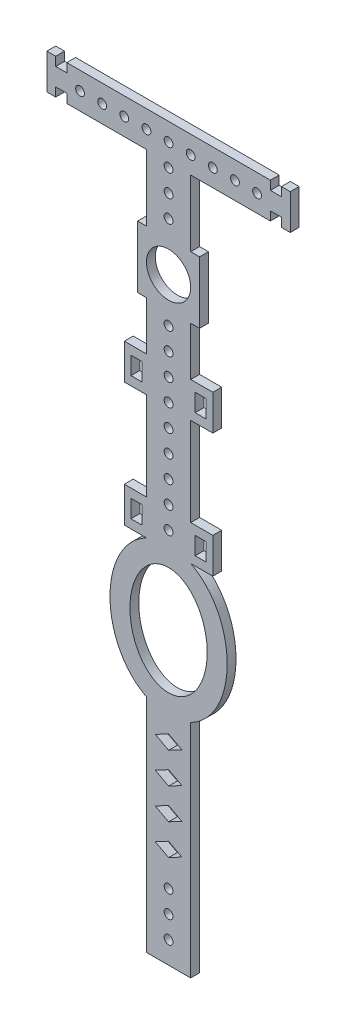
from build123d import *

# Parameters (mm, degrees)
SKETCH_1_R      = 5
SKETCH_1_R_2    = 1
SKETCH_1_W      = 2.5
SKETCH_1_H      = 4
EXTRUDE_1_DEPTH = 2


with BuildPart() as part:
    # 草图1 → 凸台-拉伸1 (new body)
    with BuildSketch(Plane.XY):
        with BuildLine():
            Line((-5, 7), (-7, 7))
            Line((-7, 7), (-7, -7))
            Line((-7, -7), (-5, -7))
            Line((-5, -7), (-5, -18))
            Line((-5, -18), (-10, -18))
            Line((-10, -18), (-10, -26))
            Line((-10, -26), (-5, -26))
            Line((-5, -26), (-5, -46))
            Line((-5, -46), (-10, -46))
            Line((-10, -46), (-10, -54))
            Line((-10, -54), (-5, -54))
            add(Edge.make_bspline(
                [(-5, -54), (-5.206631572, -54.1046163), (-7.122538881, -55.146340962), (-10.136236083, -58.053937604), (-12.460991296, -63.031081614), (-13.257864896, -67.527529667), (-13.257864896, -71.592056821), (-12.460991296, -76.088504874), (-10.136236082, -81.065648884), (-7.122538881, -83.973245525), (-5.206631571, -85.014970188), (-5, -85.119586487)],
                knots=[3.487673016, 3.487673016, 3.487673016, 3.487673016, 3.534291735, 3.926990817, 4.319689899, 4.61421421, 4.810563751, 5.105088062, 5.497787144, 5.890486225, 5.937104944, 5.937104944, 5.937104944, 5.937104944], degree=3))
            Line((-5, -85.119586487), (-5, -135.119586487))
            Line((-5, -135.119586487), (5, -135.119586487))
            Line((5, -135.119586487), (5, -85.119586487))
            add(Edge.make_bspline(
                [(5, -85.119586487), (5.206631572, -85.014970188), (7.122538881, -83.973245525), (10.136236083, -81.065648883), (12.460991296, -76.088504873), (13.257864896, -71.592056821), (13.257864896, -67.527529666), (12.460991296, -63.031081614), (10.136236082, -58.053937604), (7.122538881, -55.146340962), (5.206631571, -54.1046163), (5, -54)],
                knots=[6.62926567, 6.62926567, 6.62926567, 6.62926567, 6.675884389, 7.068583471, 7.461282552, 7.755806864, 7.952156404, 8.246680716, 8.639379797, 9.032078879, 9.078697598, 9.078697598, 9.078697598, 9.078697598], degree=3))
            Line((5, -54), (10, -54))
            Line((10, -54), (10, -46))
            Line((10, -46), (5, -46))
            Line((5, -46), (5, -26))
            Line((5, -26), (10, -26))
            Line((10, -26), (10, -18))
            Line((10, -18), (5, -18))
            Line((5, -18), (5, -7))
            Line((5, -7), (7, -7))
            Line((7, -7), (7, 7))
            Line((7, 7), (5, 7))
            Line((5, 7), (5, 22))
            Line((5, 22), (23, 22))
            Line((23, 22), (23, 24))
            Line((23, 24), (25.5, 24))
            Line((25.5, 24), (25.5, 22))
            Line((25.5, 22), (27.5, 22))
            Line((27.5, 22), (27.5, 30))
            Line((27.5, 30), (25.5, 30))
            Line((25.5, 30), (25.5, 28))
            Line((25.5, 28), (23, 28))
            Line((23, 28), (23, 30))
            Line((23, 30), (-23, 30))
            Line((-23, 30), (-23, 28))
            Line((-23, 28), (-25.5, 28))
            Line((-25.5, 28), (-25.5, 30))
            Line((-25.5, 30), (-27.5, 30))
            Line((-27.5, 30), (-27.5, 22))
            Line((-27.5, 22), (-25.5, 22))
            Line((-25.5, 22), (-25.5, 24))
            Line((-25.5, 24), (-23, 24))
            Line((-23, 24), (-23, 22))
            Line((-23, 22), (-5, 22))
            Line((-5, 22), (-5, 7))
        make_face()
        Circle(SKETCH_1_R, mode=Mode.SUBTRACT)
        with Locations((20, 25.95138361)):
            Circle(SKETCH_1_R_2, mode=Mode.SUBTRACT)
        with Locations((-20, 25.95138361)):
            Circle(SKETCH_1_R_2, mode=Mode.SUBTRACT)
        with Locations((-15, 25.95138361)):
            Circle(SKETCH_1_R_2, mode=Mode.SUBTRACT)
        with Locations((-10, 25.95138361)):
            Circle(SKETCH_1_R_2, mode=Mode.SUBTRACT)
        with Locations((-5, 25.95138361)):
            Circle(SKETCH_1_R_2, mode=Mode.SUBTRACT)
        with Locations((0, 10.95138361)):
            Circle(SKETCH_1_R_2, mode=Mode.SUBTRACT)
        with Locations((0, 15.95138361)):
            Circle(SKETCH_1_R_2, mode=Mode.SUBTRACT)
        with Locations((0, 20.95138361)):
            Circle(SKETCH_1_R_2, mode=Mode.SUBTRACT)
        with Locations((0, 25.95138361)):
            Circle(SKETCH_1_R_2, mode=Mode.SUBTRACT)
        with Locations((5, 25.95138361)):
            Circle(SKETCH_1_R_2, mode=Mode.SUBTRACT)
        with Locations((10, 25.95138361)):
            Circle(SKETCH_1_R_2, mode=Mode.SUBTRACT)
        with Locations((15, 25.95138361)):
            Circle(SKETCH_1_R_2, mode=Mode.SUBTRACT)
        with Locations((7.25, -22)):
            Rectangle(SKETCH_1_W, SKETCH_1_H, mode=Mode.SUBTRACT)
        with Locations((-7.25, -50)):
            Rectangle(SKETCH_1_W, SKETCH_1_H, mode=Mode.SUBTRACT)
        with Locations((0, -45)):
            Circle(SKETCH_1_R_2, mode=Mode.SUBTRACT)
        with Locations((0, -40)):
            Circle(SKETCH_1_R_2, mode=Mode.SUBTRACT)
        with Locations((0, -35)):
            Circle(SKETCH_1_R_2, mode=Mode.SUBTRACT)
        with Locations((-7.25, -22)):
            Rectangle(SKETCH_1_W, SKETCH_1_H, mode=Mode.SUBTRACT)
        with Locations((0, -30)):
            Circle(SKETCH_1_R_2, mode=Mode.SUBTRACT)
        with Locations((0, -25)):
            Circle(SKETCH_1_R_2, mode=Mode.SUBTRACT)
        with Locations((0, -20)):
            Circle(SKETCH_1_R_2, mode=Mode.SUBTRACT)
        with Locations((0, -15)):
            Circle(SKETCH_1_R_2, mode=Mode.SUBTRACT)
        with Locations((0, -10)):
            Circle(SKETCH_1_R_2, mode=Mode.SUBTRACT)
        with Locations((0, -50)):
            Circle(SKETCH_1_R_2, mode=Mode.SUBTRACT)
        with Locations((7.25, -50)):
            Rectangle(SKETCH_1_W, SKETCH_1_H, mode=Mode.SUBTRACT)
        with BuildLine():
            add(Edge.make_bspline(
                [(0, -81.82152984), (15.11674465, -81.82152984), (7.558372325, -63.428924948), (0, -45.036320056), (-7.558372325, -63.428924948), (-15.11674465, -81.82152984), (0, -81.82152984)],
                knots=[0, 0, 0, 2.094395102, 2.094395102, 4.188790205, 4.188790205, 6.283185307, 6.283185307, 6.283185307], degree=2, weights=[1, 0.5, 1, 0.5, 1, 0.5, 1]))
        make_face(mode=Mode.SUBTRACT)
        Polygon((0, -114.061347215), (-3, -112.457928946), (0, -110.854510677), (3, -112.457928946), align=None, mode=Mode.SUBTRACT)
        with Locations((0, -125.119586487)):
            Circle(SKETCH_1_R_2, mode=Mode.SUBTRACT)
        with Locations((0, -120.119586487)):
            Circle(SKETCH_1_R_2, mode=Mode.SUBTRACT)
        Polygon((0, -103.854510677), (3, -105.457928946), (0, -107.061347215), (-3, -105.457928946), align=None, mode=Mode.SUBTRACT)
        Polygon((0, -96.854510677), (3, -98.457928946), (0, -100.061347215), (-3, -98.457928946), align=None, mode=Mode.SUBTRACT)
        Polygon((0, -89.854510677), (3, -91.457928946), (0, -93.061347215), (-3, -91.457928946), align=None, mode=Mode.SUBTRACT)
        with Locations((0, -130.119586487)):
            Circle(SKETCH_1_R_2, mode=Mode.SUBTRACT)
    extrude(amount=EXTRUDE_1_DEPTH)


solid = part.part
